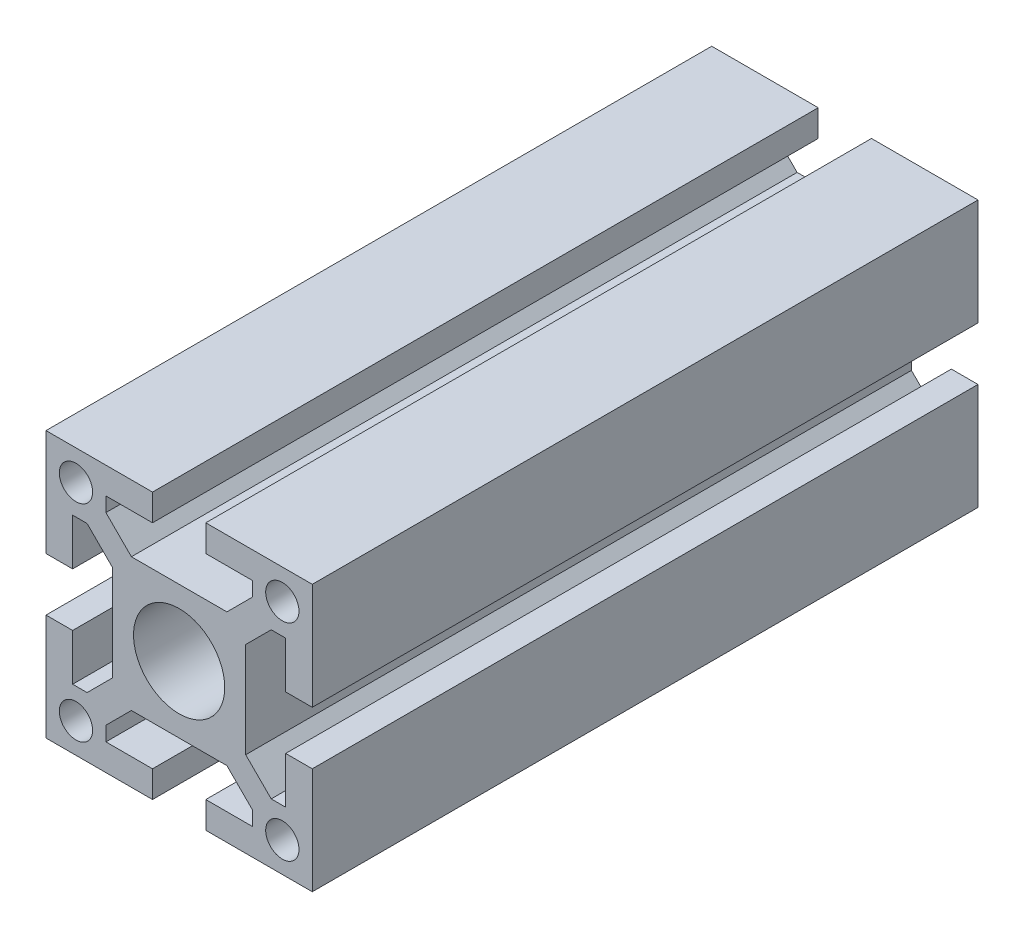
from build123d import *

# Parameters (mm, degrees)
SKETCH1_R      = 2.5
SKETCH1_R_2    = 6.85
EXTRUDE1_DEPTH = 100


with BuildPart() as part:
    # Sketch1 → Extrude1 (new body)
    with BuildSketch(Plane.XY):
        Polygon((-20, -4), (-16, -4), (-16, -11), (-13.828427, -11), (-10, -7.171573), (-10, 7.171573), (-13.828427, 11), (-16, 11), (-16, 4), (-20, 4), (-20, 20), (-4, 20), (-4, 16), (-11, 16), (-11, 13.828427), (-7.171573, 10), (7.171573, 10), (11, 13.828427), (11, 16), (4, 16), (4, 20), (20, 20), (20, 4), (16, 4), (16, 11), (13.828427, 11), (10, 7.171573), (10, -7.171573), (13.828427, -11), (16, -11), (16, -4), (20, -4), (20, -20), (4, -20), (4, -16), (11, -16), (11, -13.828427), (7.171573, -10), (-7.171573, -10), (-11, -13.828427), (-11, -16), (-4, -16), (-4, -20), (-20, -20), align=None)
        with Locations((-15.5, -15.5)):
            Circle(SKETCH1_R, mode=Mode.SUBTRACT)
        with Locations((-15.5, 15.5)):
            Circle(SKETCH1_R, mode=Mode.SUBTRACT)
        with Locations((15.5, -15.5)):
            Circle(SKETCH1_R, mode=Mode.SUBTRACT)
        with Locations((15.5, 15.5)):
            Circle(SKETCH1_R, mode=Mode.SUBTRACT)
        Circle(SKETCH1_R_2, mode=Mode.SUBTRACT)
    extrude(amount=-EXTRUDE1_DEPTH)


solid = part.part
